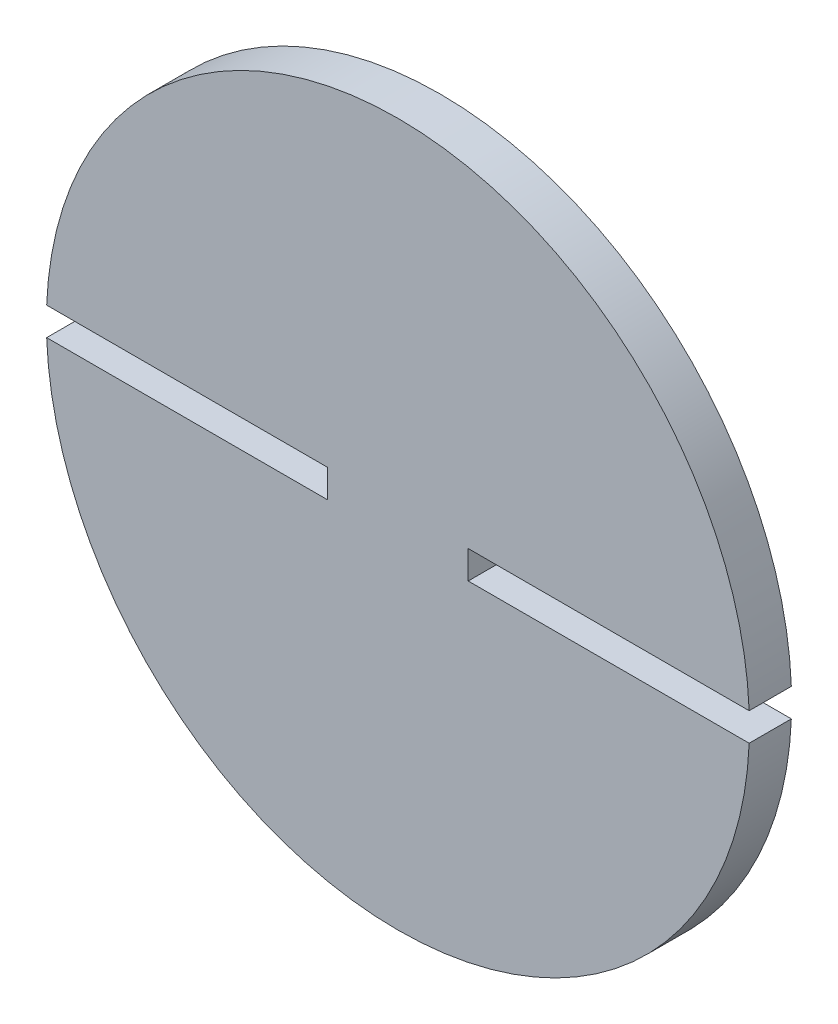
from build123d import *

# Parameters (mm, degrees)
SKETCH1_R           = 25
BOSS_EXTRUDE1_DEPTH = 3
CUT_EXTRUDE1_DEPTH  = 3


with BuildPart() as part:
    # Sketch1 → Boss-Extrude1 (new body)
    with BuildSketch(Plane.XY):
        Circle(SKETCH1_R)
    extrude(amount=BOSS_EXTRUDE1_DEPTH)

    # Sketch2 → Cut-Extrude1 (cut)
    with BuildSketch(Plane(origin=(0, 0, 0), x_dir=(-1, 0, 0), z_dir=(0, 0, -1))):
        with BuildLine():
            Line((-24.979991994, -1), (-5, -1))
            Line((-5, -1), (-5, 1))
            Line((-5, 1), (-24.979991994, 1))
            ThreePointArc((-24.979991994, 1), (-25, 0), (-24.979991994, -1))
        make_face()
        with BuildLine():
            Line((5, 1), (5, -1))
            Line((5, -1), (24.979991994, -1))
            ThreePointArc((24.979991994, -1), (24.994997498, -0.50010007), (25, 0))
            ThreePointArc((25, 0), (24.994997498, 0.50010007), (24.979991994, 1))
            Line((24.979991994, 1), (5, 1))
        make_face()
    extrude(amount=-CUT_EXTRUDE1_DEPTH, mode=Mode.SUBTRACT)


solid = part.part
